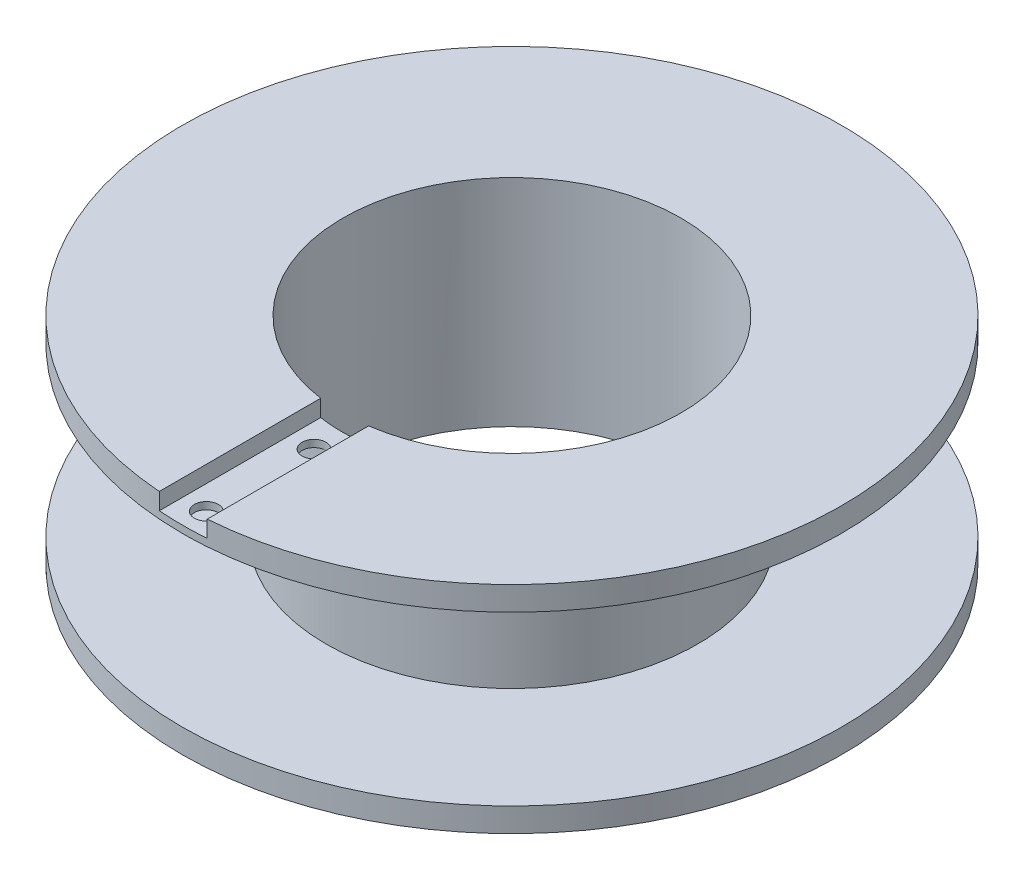
from build123d import *

# Parameters (mm, degrees)
ESQUISSE1_R             = 13.75
BOSS_EXTRU_1_DEPTH      = 9
ENL_V_START             = -1
ESQUISSE2_OUTSIDE_W     = 37.484
ESQUISSE2_OUTSIDE_H     = 37.484
ESQUISSE2_OUTSIDE_R     = 7.75
ENL_V_MAT_EXTRU_1_DEPTH = 7
ENL_V_MAT_EXTRU_2_REACH = 11
ESQUISSE3_R             = 7.05
ENL_V_MAT_EXTRU_3_REACH = 11
ESQUISSE4_R             = 0.5
ESQUISSE5_W             = 2
ESQUISSE5_H             = 15.584719065
ENL_V_MAT_EXTRU_4_DEPTH = 0.7


with BuildPart() as part:
    # Esquisse1 → Boss.-Extru.1 (new body)
    with BuildSketch(Plane(origin=(0, 0, 0), x_dir=(1, 0, 0), z_dir=(0, 1, 0))):
        with Locations(Location((0, 0, 0), (0, 0, 270))):  # turned: the seam where the file's is
            Circle(ESQUISSE1_R)
    extrude(amount=BOSS_EXTRU_1_DEPTH)

    # Esquisse2 outside → Enlèv. mat.-Extru.1 (cut)
    with BuildSketch(Plane(origin=(0, 9, 0), x_dir=(-1, 0, 0), z_dir=(0, 1, 0)).offset(ENL_V_START)):
        Rectangle(ESQUISSE2_OUTSIDE_W, ESQUISSE2_OUTSIDE_H)
        with Locations(Location((0, 0, 0), (0, 0, 90))):  # turned: the seam where the file's is
            Circle(ESQUISSE2_OUTSIDE_R, mode=Mode.SUBTRACT)
    extrude(amount=-ENL_V_MAT_EXTRU_1_DEPTH, mode=Mode.SUBTRACT)

    # Esquisse3 → Enlèv. mat.-Extru.2 (cut, up to next)
    with BuildSketch(Plane(origin=(0, 9, 0), x_dir=(-1, 0, 0), z_dir=(0, 1, 0)), mode=Mode.PRIVATE) as enl_v_mat_extru_2_sk1:
        with Locations(Location((0, 0, 0), (0, 0, 90))):  # turned: the seam where the file's is
            Circle(ESQUISSE3_R)
    enl_v_mat_extru_2_tool1 = extrude(enl_v_mat_extru_2_sk1.sketch, amount=-ENL_V_MAT_EXTRU_2_REACH, mode=Mode.PRIVATE) & part.part
    add(enl_v_mat_extru_2_tool1.solids().sort_by_distance((0, 9, 0))[0], mode=Mode.SUBTRACT)

    # Esquisse4 → Enlèv. mat.-Extru.3 (cut, up to next)
    with BuildSketch(Plane(origin=(0, 9, 0), x_dir=(-1, 0, 0), z_dir=(0, 1, 0)), mode=Mode.PRIVATE) as enl_v_mat_extru_3_sk1:
        with Locations(Location((0, 8.256283794, 0), (0, 0, 90))):  # turned: the seam where the file's is
            Circle(ESQUISSE4_R)
    enl_v_mat_extru_3_tool1 = extrude(enl_v_mat_extru_3_sk1.sketch, amount=-ENL_V_MAT_EXTRU_3_REACH, mode=Mode.PRIVATE) & part.part
    add(enl_v_mat_extru_3_tool1.solids().sort_by_distance((0, 9, 8.256284))[0], mode=Mode.SUBTRACT)
    # Esquisse4 → Enlèv. mat.-Extru.3 (cut, up to next)
    with BuildSketch(Plane(origin=(0, 9, 0), x_dir=(-1, 0, 0), z_dir=(0, 1, 0)), mode=Mode.PRIVATE) as enl_v_mat_extru_3_sk2:
        with Locations(Location((0, 12.75, 0), (0, 0, 90))):  # turned: the seam where the file's is
            Circle(ESQUISSE4_R)
    enl_v_mat_extru_3_tool2 = extrude(enl_v_mat_extru_3_sk2.sketch, amount=-ENL_V_MAT_EXTRU_3_REACH, mode=Mode.PRIVATE) & part.part
    add(enl_v_mat_extru_3_tool2.solids().sort_by_distance((0, 9, 12.75))[0], mode=Mode.SUBTRACT)

    # Esquisse5 → Enlèv. mat.-Extru.4 (cut)
    with BuildSketch(Plane(origin=(0, 9, 0), x_dir=(-1, 0, 0), z_dir=(0, 1, 0))):
        with Locations((0, 7.792359533)):
            Rectangle(ESQUISSE5_W, ESQUISSE5_H)
    extrude(amount=-ENL_V_MAT_EXTRU_4_DEPTH, mode=Mode.SUBTRACT)


solid = part.part
